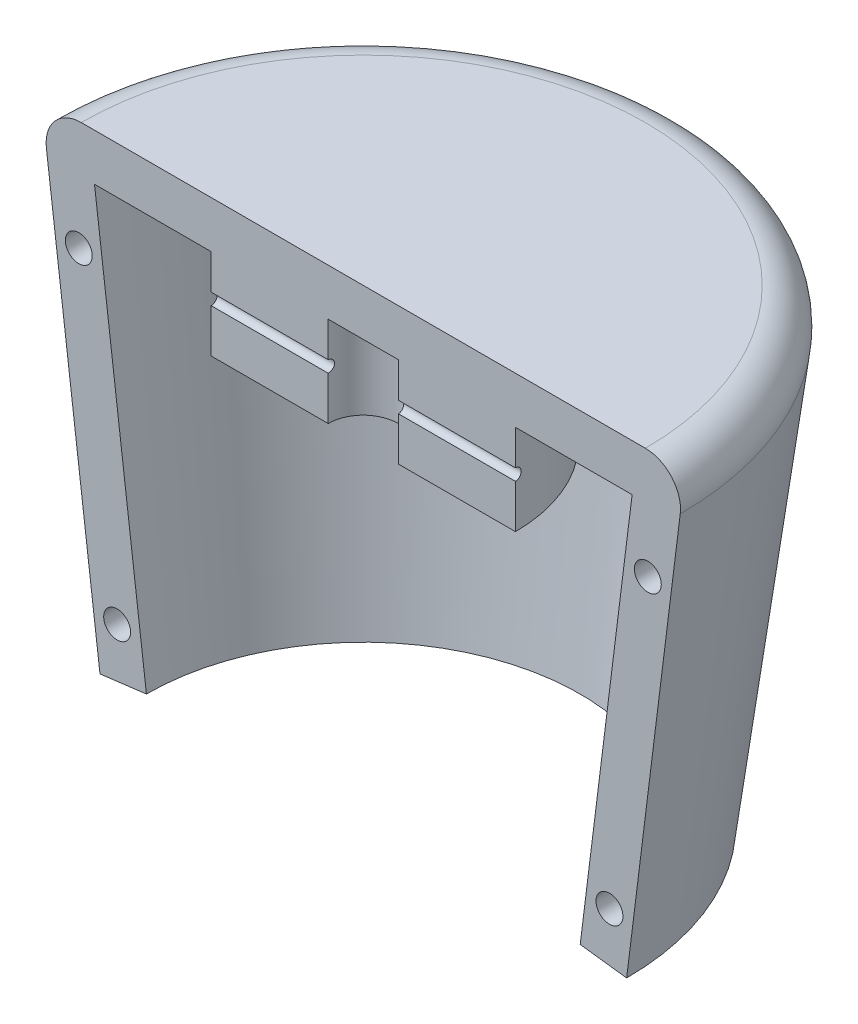
from build123d import *

# Parameters (mm, degrees)
REVOLVE1_ANGLE     = 180
FILLET1_R          = 3
SKETCH2_W          = 30
SKETCH2_H          = 0.5
SKETCH3_R          = 1.15
CUT_EXTRUDE1_DEPTH = 5


with BuildPart() as part:
    # Sketch1 → Revolve1 (revolve)
    with BuildSketch(Plane.XY):
        Polygon((0, 40), (-27.5, 40), (-22.5, 0), (-18.530888493, 0.496138938), (-22.968871126, 36), (-13, 36), (-13, 28.277027027), (-3, 28.277027027), (-3, 36), (0, 36), align=None)
    revolve(axis=Axis((0, 40, 0), (0, -1, 0)), revolution_arc=REVOLVE1_ANGLE)

    # Fillet1
    fillet1_edges = [part.edges().sort_by_distance(p)[0] for p in [
        (0, 40, -27.5),
    ]]
    fillet(fillet1_edges, radius=FILLET1_R)

    # Sketch2 → Cut-Revolve1 (revolve, cut)
    with BuildSketch(Plane.XY):
        with Locations((1, 32.75)):
            Rectangle(SKETCH2_W, SKETCH2_H)
    revolve(axis=Axis((-14, 32.5, 0), (1, 0, 0)), mode=Mode.SUBTRACT)

    # Sketch3 → Cut-Extrude1 (cut)
    with BuildSketch(Plane.XY):
        with Locations((-24.309743639, 30.602464611)):
            Circle(SKETCH3_R)
        with Locations((-21.033834323, 4.395190082)):
            Circle(SKETCH3_R)
        with Locations((21.033834323, 4.395190082)):
            Circle(SKETCH3_R)
        with Locations((24.309743639, 30.602464611)):
            Circle(SKETCH3_R)
    extrude(amount=-CUT_EXTRUDE1_DEPTH, mode=Mode.SUBTRACT)


solid = part.part
